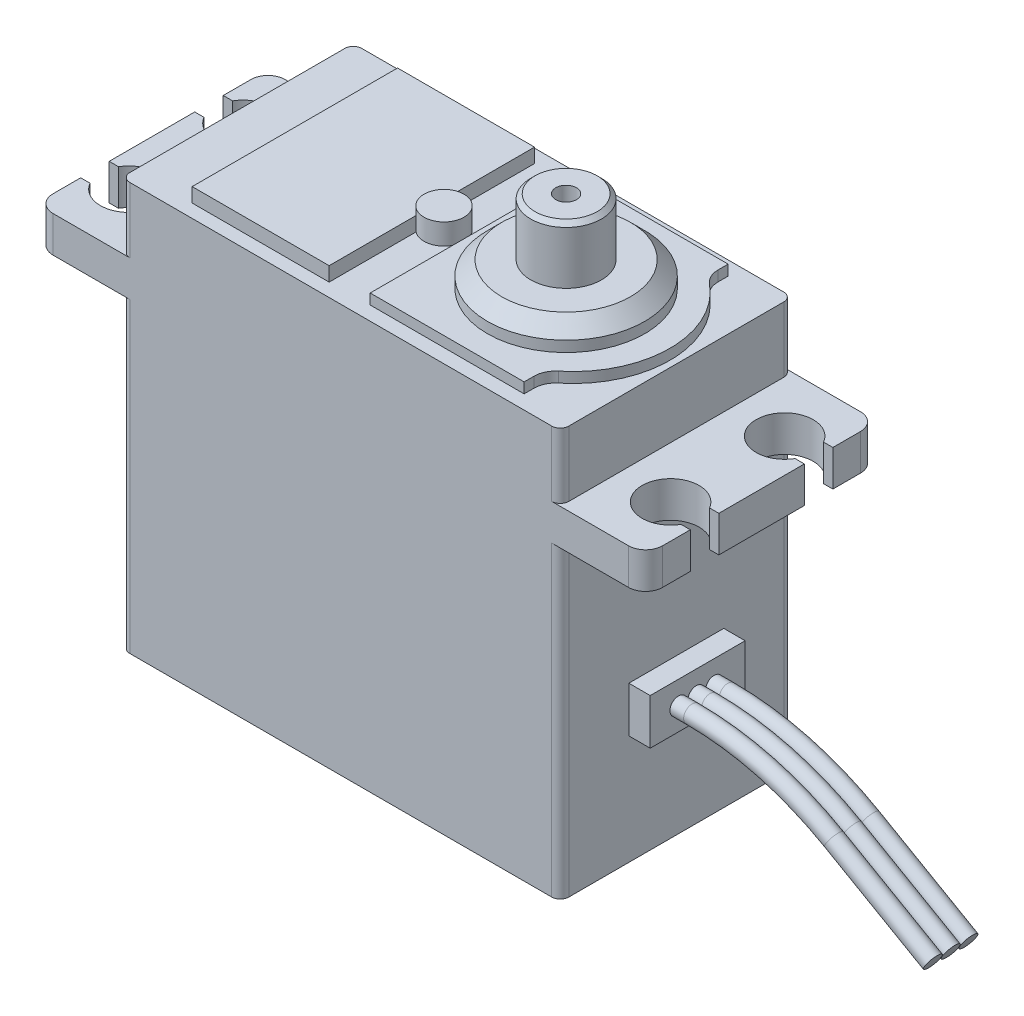
from build123d import *

# Parameters (mm, degrees)
SKETCH1_W           = 30.8
SKETCH1_H           = 16.28
BOSS_EXTRUDE1_DEPTH = 28.62
SKETCH3_W           = 5.985
SKETCH3_H           = 2.53
BOSS_EXTRUDE2_DEPTH = 16.28
SKETCH4_W           = 9.61
SKETCH4_H           = 14.41
BOSS_EXTRUDE3_DEPTH = 1
BOSS_EXTRUDE4_DEPTH = 0.73
SKETCH6_R           = 5.52
BOSS_EXTRUDE5_DEPTH = 1.75
CHAMFER1_SIZE       = 1
FILLET1_R           = 1.5
SKETCH7_R           = 1.4
BOSS_EXTRUDE6_DEPTH = 1.47
SKETCH8_R           = 2.48
BOSS_EXTRUDE7_DEPTH = 4
CUT_EXTRUDE1_DEPTH  = 4
SKETCH10_W          = 6.66
SKETCH10_H          = 3.2
BOSS_EXTRUDE8_DEPTH = 1.5
SKETCH11_R          = 0.6
FILLET2_R           = 1.2
FILLET3_R           = 0.6
CHAMFER2_SIZE       = 0.3
SKETCH13_R          = 0.726441042
CUT_EXTRUDE2_DEPTH  = 2.5


with BuildPart() as part:
    # Sketch1 → Boss-Extrude1 (new body)
    with BuildSketch(Plane(origin=(0, 0, 0), x_dir=(1, 0, 0), z_dir=(0, 1, 0))):
        with Locations((15.4, 8.14)):
            Rectangle(SKETCH1_W, SKETCH1_H)
    extrude(amount=BOSS_EXTRUDE1_DEPTH)

    # Sketch3 → Boss-Extrude2 (add)
    with BuildSketch(Plane.XY):
        with Locations((33.7925, 22.775)):
            Rectangle(SKETCH3_W, SKETCH3_H)
        with Locations((-2.9925, 22.775)):
            Rectangle(SKETCH3_W, SKETCH3_H)
    extrude(amount=-BOSS_EXTRUDE2_DEPTH)

    # Sketch4 → Boss-Extrude3 (add)
    with BuildSketch(Plane(origin=(0, 28.62, 0), x_dir=(1, 0, 0), z_dir=(0, 1, 0))):
        with Locations((8.845, 8.14)):
            Rectangle(SKETCH4_W, SKETCH4_H)
    extrude(amount=BOSS_EXTRUDE3_DEPTH)

    # Sketch5 → Boss-Extrude4 (add)
    with BuildSketch(Plane(origin=(0, 28.62, 0), x_dir=(1, 0, 0), z_dir=(0, 1, 0))):
        with BuildLine():
            Line((27.28, 0.985), (16.48, 0.985))
            Line((16.48, 0.985), (16.48, 15.295))
            Line((16.48, 15.295), (27.28, 15.295))
            Line((27.28, 15.295), (27.28, 13.838504907))
            ThreePointArc((27.28, 13.838504907), (30.36, 8.14), (27.28, 2.441495093))
            Line((27.28, 2.441495093), (27.28, 0.985))
        make_face()
    extrude(amount=BOSS_EXTRUDE4_DEPTH)

    # Sketch6 → Boss-Extrude5 (add)
    with BuildSketch(Plane(origin=(0, 29.35, 0), x_dir=(1, 0, 0), z_dir=(0, 1, 0))):
        with Locations((23.07, 8.14)):
            Circle(SKETCH6_R)
    extrude(amount=BOSS_EXTRUDE5_DEPTH)

    # Chamfer1
    chamfer1_edges = [part.edges().sort_by_distance(p)[0] for p in [
        (17.55, 31.1, -8.14),
    ]]
    chamfer(chamfer1_edges, length=CHAMFER1_SIZE)

    # Fillet1
    fillet1_edges = [part.edges().sort_by_distance(p)[0] for p in [
        (27.28, 28.985, -2.441495093),
        (27.28, 28.985, -13.838504907),
    ]]
    fillet(fillet1_edges, radius=FILLET1_R)

    # Sketch7 → Boss-Extrude6 (add)
    with BuildSketch(Plane(origin=(0, 28.62, 0), x_dir=(1, 0, 0), z_dir=(0, 1, 0))):
        with Locations((14.504271984, 8.14)):
            Circle(SKETCH7_R)
    extrude(amount=BOSS_EXTRUDE6_DEPTH)

    # Sketch8 → Boss-Extrude7 (add)
    with BuildSketch(Plane(origin=(0, 31.1, 0), x_dir=(1, 0, 0), z_dir=(0, 1, 0))):
        with Locations((23.07, 8.14)):
            Circle(SKETCH8_R)
    extrude(amount=BOSS_EXTRUDE7_DEPTH)

    # Sketch9 → Cut-Extrude1 (cut)
    with BuildSketch(Plane(origin=(0, 24.04, 0), x_dir=(1, 0, 0), z_dir=(0, 1, 0))):
        with BuildLine():
            Line((37.246499074, 13.14), (37.246499074, 11.14))
            Line((37.246499074, 11.14), (36.132050808, 11.14))
            ThreePointArc((36.132050808, 11.14), (32.4, 12.14), (36.132050808, 13.14))
            Line((36.132050808, 13.14), (37.246499074, 13.14))
        make_face()
        with BuildLine():
            Line((36.132050808, 3.14), (37.246499074, 3.14))
            Line((37.246499074, 3.14), (37.246499074, 5.14))
            Line((37.246499074, 5.14), (36.132050808, 5.14))
            ThreePointArc((36.132050808, 5.14), (32.4, 4.14), (36.132050808, 3.14))
        make_face()
        with BuildLine():
            Line((-5.332050808, 5.14), (-6.446499074, 5.14))
            Line((-6.446499074, 5.14), (-6.446499074, 3.14))
            Line((-6.446499074, 3.14), (-5.332050808, 3.14))
            ThreePointArc((-5.332050808, 3.14), (-1.6, 4.14), (-5.332050808, 5.14))
        make_face()
        with BuildLine():
            Line((-5.332050808, 13.14), (-6.446499074, 13.14))
            Line((-6.446499074, 13.14), (-6.446499074, 11.14))
            Line((-6.446499074, 11.14), (-5.332050808, 11.14))
            ThreePointArc((-5.332050808, 11.14), (-1.6, 12.14), (-5.332050808, 13.14))
        make_face()
    extrude(amount=-CUT_EXTRUDE1_DEPTH, mode=Mode.SUBTRACT)

    # Sketch10 → Boss-Extrude8 (add)
    with BuildSketch(Plane(origin=(30.8, 0, 0), x_dir=(0, 0, -1), z_dir=(1, 0, 0))):
        with Locations((8.14, 9.29)):
            Rectangle(SKETCH10_W, SKETCH10_H)
    extrude(amount=BOSS_EXTRUDE8_DEPTH)

    # Sweep1: sweep along a path in Sketch12
    with BuildLine(Plane(origin=(0, 0, -8.14), x_dir=(-1, 0, 0), z_dir=(0, 0, -1))) as sweep1_path:
        Line((-32.3, 9.27453939), (-33.261270846, 9.27453939))
        ThreePointArc((-33.261270846, 9.27453939), (-38.407623516, 8.601076954), (-43.207388666, 6.626044809))
        Line((-43.207388666, 6.626044809), (-50.146426146, 2.648494581))
    # Sketch11 → Sweep1 (sweep)
    with BuildSketch(Plane(origin=(32.3, 0, 0), x_dir=(0, 0, -1), z_dir=(1, 0, 0))):
        with Locations((6.7940488, 9.27453939)):
            Circle(SKETCH11_R)
        with Locations((8.045254391, 9.27453939)):
            Circle(SKETCH11_R)
        with Locations((9.289971537, 9.27453939)):
            Circle(SKETCH11_R)
    sweep(path=sweep1_path.line)

    # Fillet2
    fillet2_edges = [part.edges().sort_by_distance(p)[0] for p in [
        (-5.985, 22.775, 0),
        (-5.985, 22.775, -16.28),
        (36.785, 22.775, 0),
        (36.785, 22.775, -16.28),
    ]]
    fillet(fillet2_edges, radius=FILLET2_R)

    # Fillet3
    fillet3_edges = [part.edges().sort_by_distance(p)[0] for p in [
        (0, 26.33, 0),
        (0, 10.755, 0),
        (30.8, 10.755, 0),
        (0, 10.755, -16.28),
        (0, 26.33, -16.28),
        (30.8, 26.33, 0),
        (30.8, 26.33, -16.28),
        (30.8, 10.755, -16.28),
    ]]
    fillet(fillet3_edges, radius=FILLET3_R)

    # Chamfer2
    chamfer2_edges = [part.edges().sort_by_distance(p)[0] for p in [
        (20.59, 35.1, -8.14),
    ]]
    chamfer(chamfer2_edges, length=CHAMFER2_SIZE)

    # Sketch13 → Cut-Extrude2 (cut)
    with BuildSketch(Plane(origin=(0, 35.1, 0), x_dir=(1, 0, 0), z_dir=(0, 1, 0))):
        with Locations((23.07, 8.14)):
            Circle(SKETCH13_R)
    extrude(amount=-CUT_EXTRUDE2_DEPTH, mode=Mode.SUBTRACT)


solid = part.part
